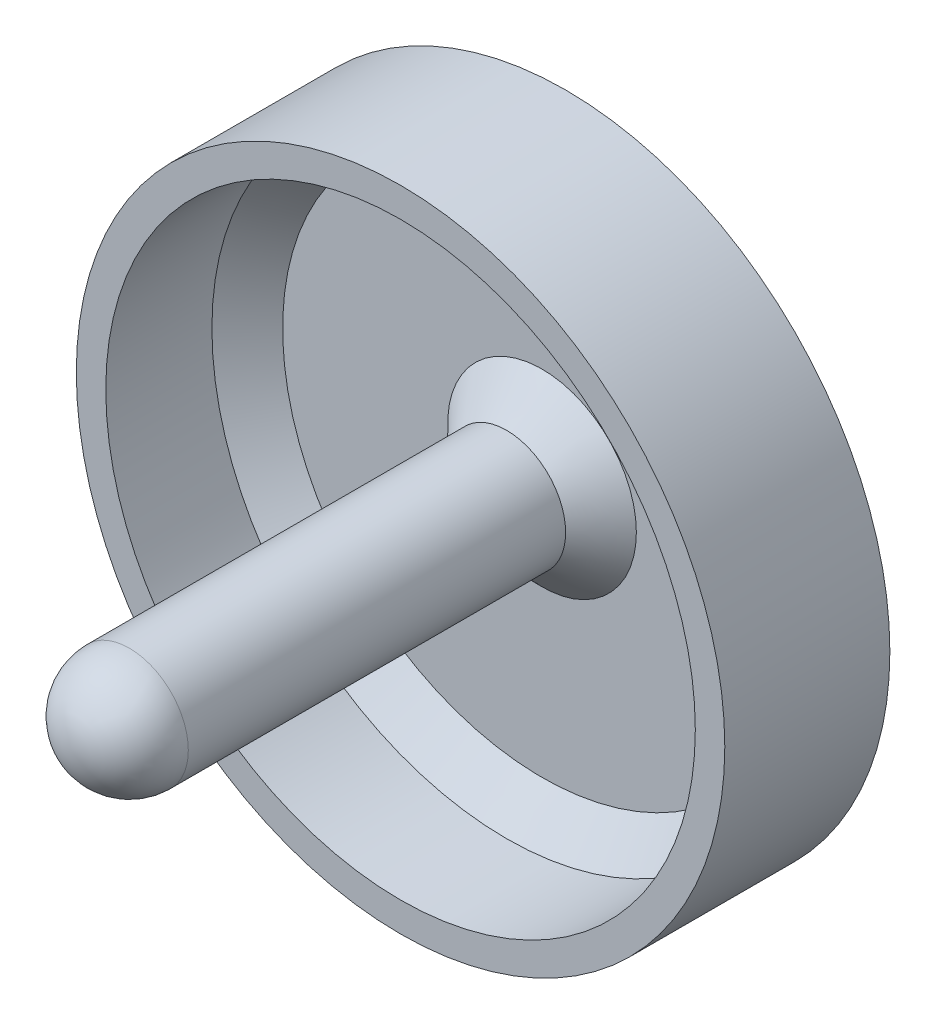
from build123d import *

# Parameters (mm, degrees)
SKETCH_1_R      = 27.5
EXTRUDE_1_DEPTH = 2
SKETCH_2_R      = 27.5
SKETCH_2_R_2    = 25
EXTRUDE_2_DEPTH = 12
SKETCH_3_R      = 5
EXTRUDE_3_DEPTH = 40
CHAMFER_2_SIZE  = 3
CHAMFER_3_SIZE  = 3
FILLET_3_R      = 5


with BuildPart() as part:
    # 草图1 → 凸台-拉伸1 (new body)
    with BuildSketch(Plane.XY):
        Circle(SKETCH_1_R)
    extrude(amount=EXTRUDE_1_DEPTH)

    # 草图2 → 凸台-拉伸2 (add)
    with BuildSketch(Plane.XY.offset(2)):
        Circle(SKETCH_2_R)
        Circle(SKETCH_2_R_2, mode=Mode.SUBTRACT)
    extrude(amount=EXTRUDE_2_DEPTH)

    # 草图3 → 凸台-拉伸3 (add)
    with BuildSketch(Plane.XY.offset(2)):
        Circle(SKETCH_3_R)
    extrude(amount=EXTRUDE_3_DEPTH)

    # 倒角2
    chamfer_2_edges = [part.edges().sort_by_distance(p)[0] for p in [
        (-25, 0, 2),
    ]]
    chamfer(chamfer_2_edges, length=CHAMFER_2_SIZE)

    # 倒角3
    chamfer_3_edges = [part.edges().sort_by_distance(p)[0] for p in [
        (-5, 0, 2),
    ]]
    chamfer(chamfer_3_edges, length=CHAMFER_3_SIZE)

    # 圆角3
    fillet_3_edges = [part.edges().sort_by_distance(p)[0] for p in [
        (-5, 0, 42),
    ]]
    fillet(fillet_3_edges, radius=FILLET_3_R)


solid = part.part
